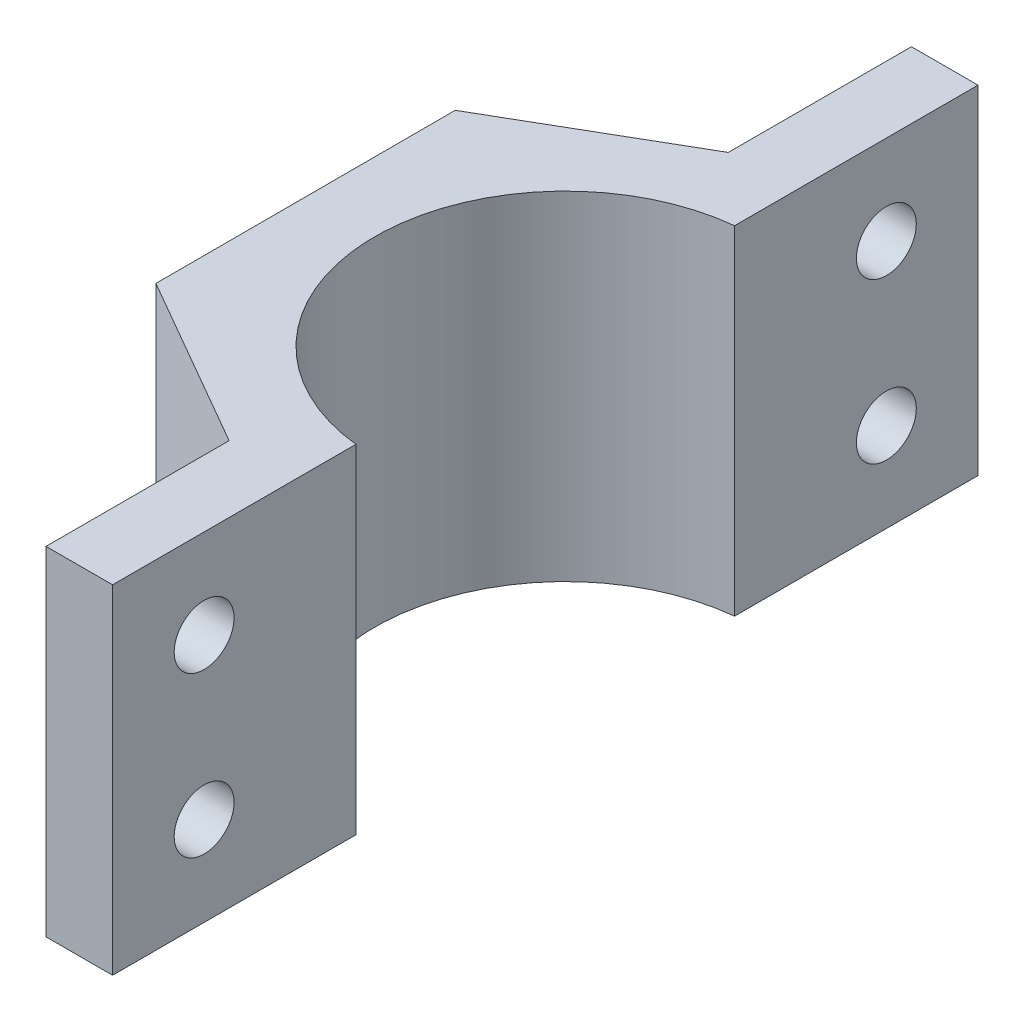
from build123d import *

# Parameters (mm, degrees)
BOSS_EXTRUDE1_DEPTH = 25.4
SKETCH2_R           = 2.25
CUT_EXTRUDE1_DEPTH  = 6


with BuildPart() as part:
    # Sketch1 → Boss-Extrude1 (new body)
    with BuildSketch(Plane(origin=(0, 0, 0), x_dir=(1, 0, 0), z_dir=(0, 1, 0))):
        Polygon((-6.5, 18.750739811), (-1.5, 21.642901866), (-1.5, 32.503507515), (-6.5, 32.503507515), align=None)
        with BuildLine():
            Line((-1.5, -21.625070485), (-1.5, -14.221111068))
            ThreePointArc((-1.5, -14.221111068), (-14.3, 0), (-1.5, 14.221111068))
            Line((-1.5, 14.221111068), (-1.5, 21.642901866))
            Line((-1.5, 21.642901866), (-6.5, 18.750739811))
            Line((-6.5, 18.750739811), (-19.494691465, 11.234189098))
            Line((-19.494691465, 11.234189098), (-19.476438882, -11.265803499))
            Line((-19.476438882, -11.265803499), (-6.5, -18.743724782))
            Line((-6.5, -18.743724782), (-1.5, -21.625070485))
        make_face()
        Polygon((-1.5, -32.496492485), (-1.5, -21.625070485), (-6.5, -18.743724782), (-6.5, -32.496492485), align=None)
    extrude(amount=BOSS_EXTRUDE1_DEPTH)

    # Sketch2 → Cut-Extrude1 (cut, through all)
    with BuildSketch(Plane.ZY.offset(6.5)):
        with Locations((25.620108634, 18.7)):
            Circle(SKETCH2_R)
        with Locations((25.620108634, 6.7)):
            Circle(SKETCH2_R)
    cut_extrude1 = extrude(amount=-CUT_EXTRUDE1_DEPTH, mode=Mode.SUBTRACT)

    # Mirror1: Cut-Extrude1 across plane
    add(cut_extrude1.mirror(Plane.XY), mode=Mode.SUBTRACT)


solid = part.part
